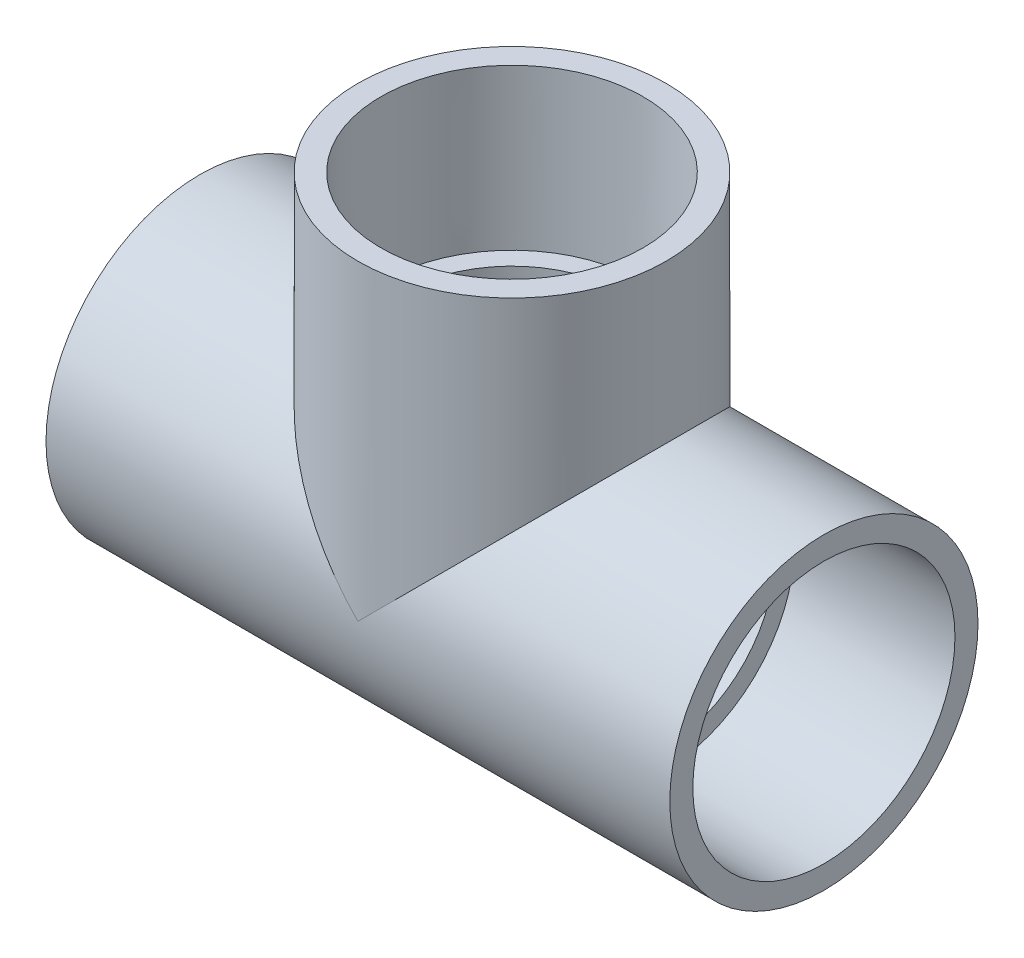
from build123d import *

# Parameters (mm, degrees)
SKETCH3_R           = 28.5496
BOSS_EXTRUDE1_DEPTH = 56.5404
SKETCH4_R           = 28.5496
BOSS_EXTRUDE2_DEPTH = 28.2702


with BuildPart() as part:
    # Sketch1 → Revolve1 (revolve)
    with BuildSketch(Plane.XY):
        Polygon((-57.785, -28.5496), (-28.2702, -28.5496), (-28.2702, -24.0538), (-57.785, -24.2824), align=None)
        Polygon((57.785, -24.2824), (28.2702, -24.0538), (28.2702, -28.5496), (57.785, -28.5496), align=None)
    revolve(axis=Axis((-57.785, 0, 0), (1, 0, 0)))



with BuildPart() as body_2:
    # Sketch2 → Revolve2 (revolve)
    with BuildSketch(Plane.XY):
        Polygon((24.2824, 57.785), (24.0538, 28.2702), (28.5496, 28.2702), (28.5496, 57.785), align=None)
    revolve(axis=Axis((0, 0, 0), (0, 1, 0)))


with BuildPart() as part_1:
    add(part.part)

    add(body_2.part)  # Boss-Extrude1 merges body 2
    # Sketch3 → Boss-Extrude1 (add)
    with BuildSketch(Plane(origin=(-28.2702, 0, 0), x_dir=(0, 0, -1), z_dir=(1, 0, 0))):
        Circle(SKETCH3_R)
    extrude(amount=BOSS_EXTRUDE1_DEPTH)

    # Sketch4 → Boss-Extrude2 (add)
    with BuildSketch(Plane.XZ.offset(-28.2702)):
        Circle(SKETCH4_R)
    extrude(amount=BOSS_EXTRUDE2_DEPTH)

    # Sketch5 → Cut-Revolve1 (revolve, cut)
    with BuildSketch(Plane.XY):
        Polygon((-57.785, -24.2824), (-28.2702, -24.0538), (-28.2702, -20.447), (28.2702, -20.447), (28.2702, -24.0538), (57.785, -24.2824), (57.785, 0), (-57.785, 0), align=None)
    revolve(axis=Axis((57.785, 0, 0), (-1, 0, 0)), mode=Mode.SUBTRACT)

    # Sketch6 → Cut-Revolve2 (revolve, cut)
    with BuildSketch(Plane.XY):
        Polygon((24.2824, 57.785), (24.0538, 28.2702), (20.447, 28.2702), (20.447, 0), (0, 0), (0, 57.785), align=None)
    revolve(axis=Axis((0, 0, 0), (0, 1, 0)), mode=Mode.SUBTRACT)


solid = part_1.part
